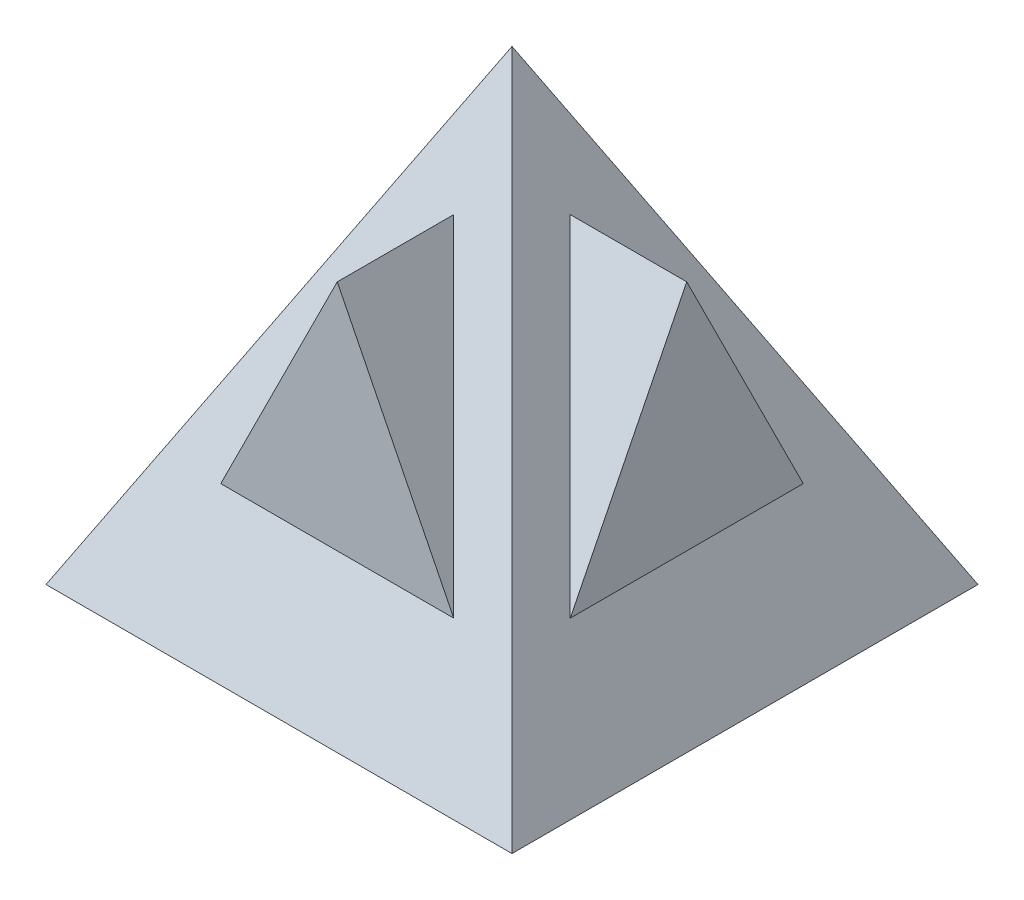
from build123d import *

# Parameters (mm, degrees)
SKETCH1_W             = 8
SKETCH1_H             = 8
BOSS_EXTRUDE1_DEPTH   = 3
BODY_MOVE_COPY1_ANGLE = 90


with BuildPart() as part:
    # Sketch1 → Loft1 section 0
    with BuildSketch(Plane(origin=(0, 0, 0), x_dir=(1, 0, 0), z_dir=(0, 1, 0)), mode=Mode.PRIVATE) as loft1_s0:
        Rectangle(SKETCH1_W, SKETCH1_H)
    loft([Vertex(0, 8, 0), loft1_s0.sketch])


with BuildPart() as body_2:
    # Sketch5 → Boss-Extrude1 (new body)
    with BuildSketch(Plane.XY):
        Polygon((0, 6), (-2, 2), (2, 2), align=None)
    extrude(amount=BOSS_EXTRUDE1_DEPTH)


with BuildPart() as body_3:
    # Body-Move/Copy1: copy of body 2
    add(body_2.part.rotate(Axis((0, 0, 0), (0, 1, 0)), BODY_MOVE_COPY1_ANGLE))


with BuildPart() as part_1:
    add(part.part)

    # Combine1: union body 2, body 3
    add(body_2.part)
    add(body_3.part)


solid = part_1.part
